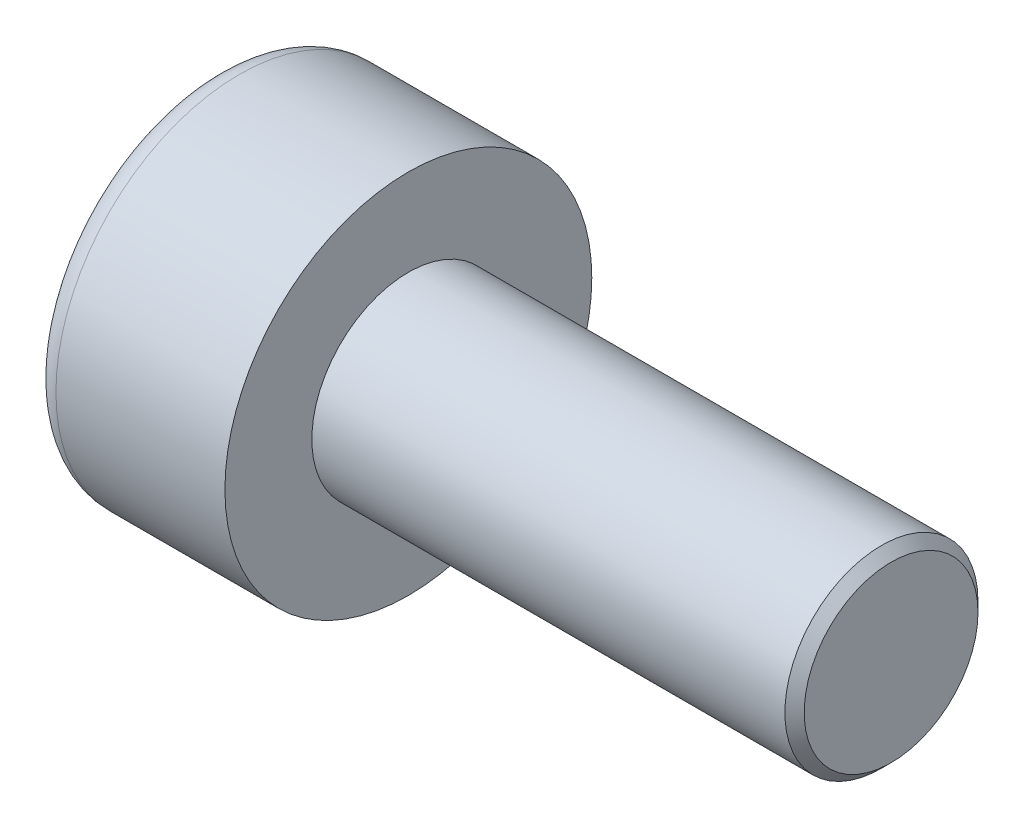
from build123d import *

# Parameters (mm, degrees)
SKETCH1_R           = 1.9
BASEHEAD_DEPTH      = 2
SKETCH2_R           = 1
BASEBODY_DEPTH      = 5
HEXAGONSOCKET_DEPTH = 1
TOPFILLET_R         = 0.25
CHAMFER1_SIZE       = 0.1


with BuildPart() as part:
    # Sketch1 → BaseHead (new body)
    with BuildSketch(Plane(origin=(0, 0, 0), x_dir=(0, 0, -1), z_dir=(1, 0, 0))):
        Circle(SKETCH1_R)
    extrude(amount=BASEHEAD_DEPTH)

    # Sketch2 → BaseBody (add)
    with BuildSketch(Plane(origin=(2, 0, 0), x_dir=(0, 0, -1), z_dir=(1, 0, 0))):
        Circle(SKETCH2_R)
    extrude(amount=BASEBODY_DEPTH)

    # Sketch3 → HexagonSocket (cut)
    with BuildSketch(Plane(origin=(0, 0, 0), x_dir=(0, 0, -1), z_dir=(1, 0, 0))):
        Polygon((0.866025404, 0), (0.433012702, 0.75), (-0.433012702, 0.75), (-0.866025404, 0), (-0.433012702, -0.75), (0.433012702, -0.75), align=None)
    extrude(amount=HEXAGONSOCKET_DEPTH, mode=Mode.SUBTRACT)

    # Sketch4 → Cut-Revolve1 (revolve, cut)
    with BuildSketch(Plane(origin=(-4.19613823, 0.75, 0), x_dir=(-1, 0, 0), z_dir=(0, 0, 1))):
        Polygon((-5.19613823, 1.5), (-5.629150931, 0.75), (-5.19613823, 0.75), align=None)
    revolve(axis=Axis((0.838992387, 0, 0), (-1, 0, 0)), mode=Mode.SUBTRACT)

    # TopFillet
    topfillet_edges = [part.edges().sort_by_distance(p)[0] for p in [
        (0, 0, 1.9),
    ]]
    fillet(topfillet_edges, radius=TOPFILLET_R)

    # Chamfer1
    chamfer1_edges = [part.edges().sort_by_distance(p)[0] for p in [
        (7, 0, 1),
    ]]
    chamfer(chamfer1_edges, length=CHAMFER1_SIZE)


solid = part.part
